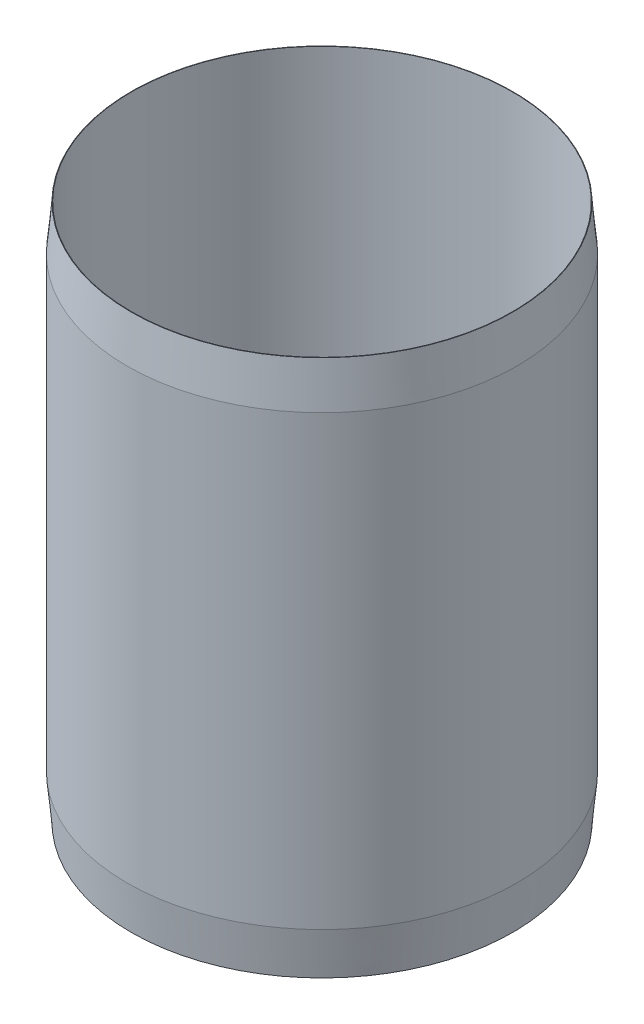
from build123d import *

# Parameters (mm, degrees)
SKETCH1_R           = 43.55
SKETCH1_R_2         = 42.55
BOSS_EXTRUDE1_DEPTH = 120
CHAMFER1_SIZE       = 10
CHAMFER1_SIZE2      = 0.9
CHAMFER2_SIZE       = 0.9
CHAMFER2_SIZE2      = 10


with BuildPart() as part:
    # Sketch1 → Boss-Extrude1 (new body)
    with BuildSketch(Plane(origin=(0, 0, 0), x_dir=(1, 0, 0), z_dir=(0, 1, 0))):
        Circle(SKETCH1_R)
        Circle(SKETCH1_R_2, mode=Mode.SUBTRACT)
    extrude(amount=BOSS_EXTRUDE1_DEPTH)

    # Chamfer1
    chamfer1_edges = [part.edges().sort_by_distance(p)[0] for p in [
        (-43.55, 120, 0),
    ]]
    chamfer1_side = [part.faces().sort_by_distance(p)[0] for p in [
        (-43.55, 60, 0),
    ]]
    chamfer(chamfer1_edges, length=CHAMFER1_SIZE, length2=CHAMFER1_SIZE2, reference=chamfer1_side[0])

    # Chamfer2
    chamfer2_edges = [part.edges().sort_by_distance(p)[0] for p in [
        (-43.55, 0, 0),
    ]]
    chamfer2_side = [part.faces().sort_by_distance(p)[0] for p in [
        (-43.426821999, 0, 0),
    ]]
    chamfer(chamfer2_edges, length=CHAMFER2_SIZE, length2=CHAMFER2_SIZE2, reference=chamfer2_side[0])


solid = part.part
